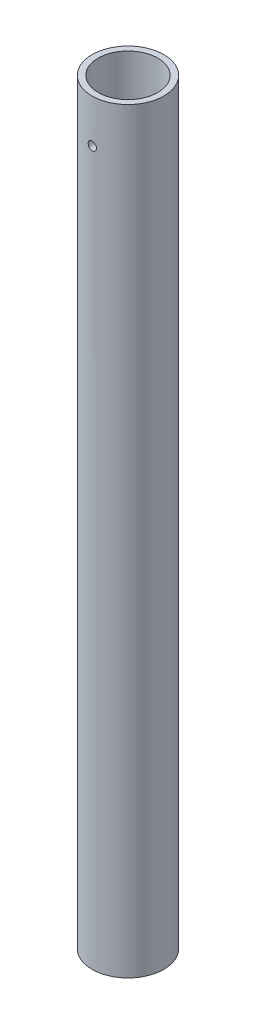
from build123d import *

# Parameters (mm, degrees)
SKETCH1_R                    = 21.082
SKETCH1_R_2                  = 17.526
BOSS_EXTRUDE1_DEPTH          = 444.5
F_10_0_1935_DIAMETER_HOLE1_D = 4.9149


with BuildPart() as part:
    # Sketch1 → Boss-Extrude1 (new body)
    with BuildSketch(Plane(origin=(0, 0, 0), x_dir=(1, 0, 0), z_dir=(0, 1, 0))):
        Circle(SKETCH1_R)
        Circle(SKETCH1_R_2, mode=Mode.SUBTRACT)
    extrude(amount=BOSS_EXTRUDE1_DEPTH)

    # #10 (0.1935) Diameter Hole1 (through all)
    with Locations(Plane.XY.offset(21.082)):
        with Locations((0, 419.1)):
            Hole(F_10_0_1935_DIAMETER_HOLE1_D / 2)


solid = part.part
